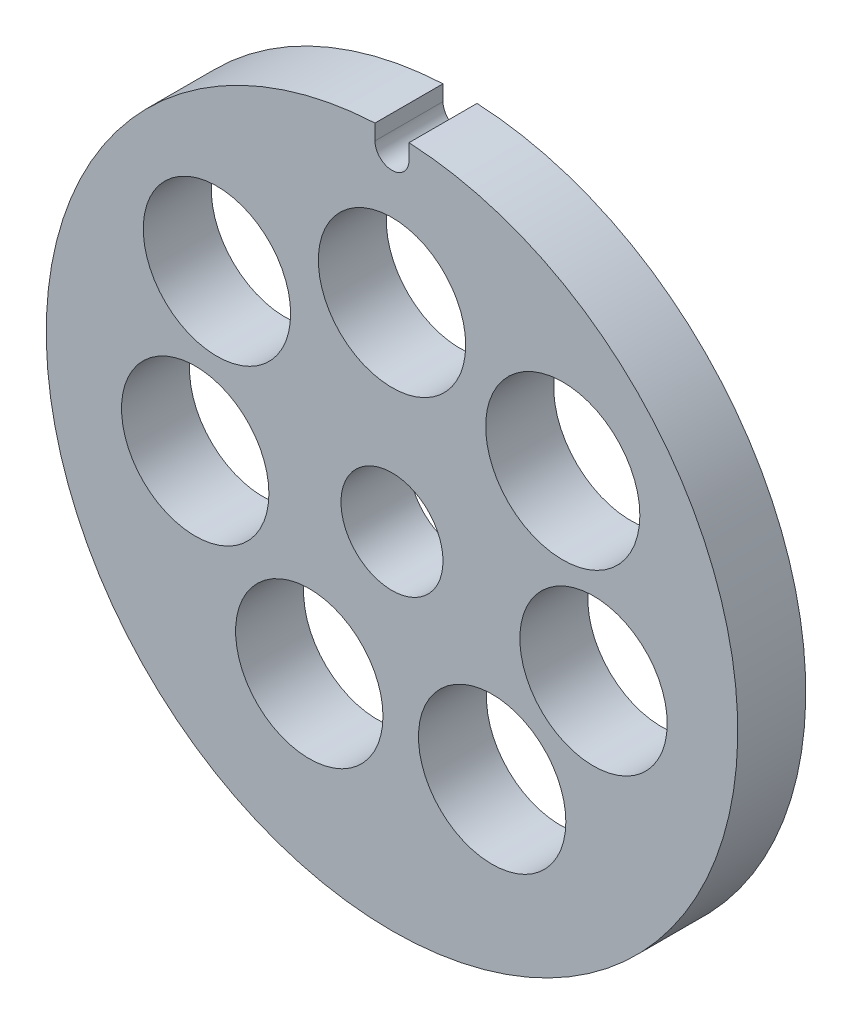
from build123d import *

# Parameters (mm, degrees)
SZKIC1_R                    = 6.5
SZKIC1_R_2                  = 4.5
SZKIC1_R_3                  = 6.800419073
DODANIE_WYCI_GNI_CIE1_DEPTH = 6


with BuildPart() as part:
    # Szkic1 → Dodanie-wyciągnięcie1 (new body)
    with BuildSketch(Plane.XY):
        with BuildLine():
            ThreePointArc((10.70117022, 18.531289035), (2.291892255, 39.56102988), (-18.29882978, 48.994381459))
            Line((-18.29882978, 48.994381459), (-18.29882978, 47.631289035))
            ThreePointArc((-18.29882978, 47.631289035), (-19.79882978, 46.131289035), (-21.29882978, 47.631289035))
            Line((-21.29882978, 47.631289035), (-21.29882978, 48.994381459))
            ThreePointArc((-21.29882978, 48.994381459), (-40.828570624, -3.559432999), (10.70117022, 18.531289035))
        make_face()
        with Locations((-37.156723858, 16.008369355)):
            Circle(SZKIC1_R, mode=Mode.SUBTRACT)
        with Locations((-27.094885778, 4.029990689)):
            Circle(SZKIC1_R, mode=Mode.SUBTRACT)
        with Locations((-10.964002507, 4.029990689)):
            Circle(SZKIC1_R, mode=Mode.SUBTRACT)
        with Locations((-19.79882978, 18.531289035)):
            Circle(SZKIC1_R_2, mode=Mode.SUBTRACT)
        with Locations((-2.020146436, 16.008369355)):
            Circle(SZKIC1_R, mode=Mode.SUBTRACT)
        with Locations((-35.240183271, 30.701847186)):
            Circle(SZKIC1_R, mode=Mode.SUBTRACT)
        with Locations((-4.7352456, 30.701847186)):
            Circle(SZKIC1_R_3, mode=Mode.SUBTRACT)
        with Locations((-19.797413553, 36.031288978)):
            Circle(SZKIC1_R, mode=Mode.SUBTRACT)
    extrude(amount=DODANIE_WYCI_GNI_CIE1_DEPTH)


solid = part.part
